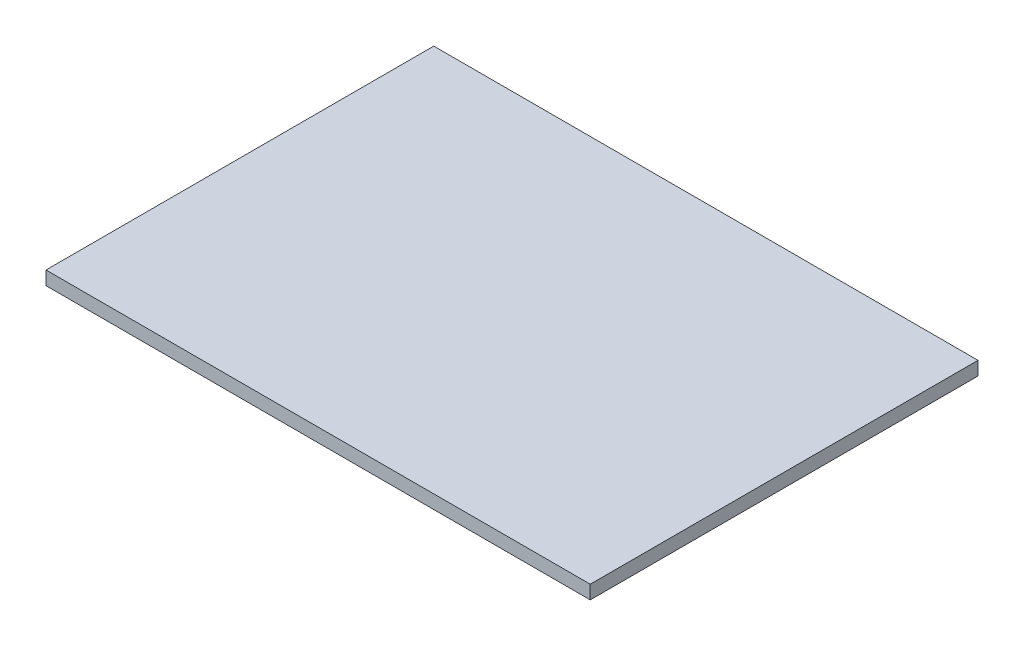
from build123d import *

# Parameters (mm, degrees)
SKETCH1_W      = 800
SKETCH1_H      = 570
EXTRUDE1_DEPTH = 20


with BuildPart() as part:
    # Sketch1 → Extrude1 (new body)
    with BuildSketch(Plane(origin=(0, 0, 0), x_dir=(1, 0, 0), z_dir=(0, 1, 0))):
        Rectangle(SKETCH1_W, SKETCH1_H)
    extrude(amount=EXTRUDE1_DEPTH)


solid = part.part
